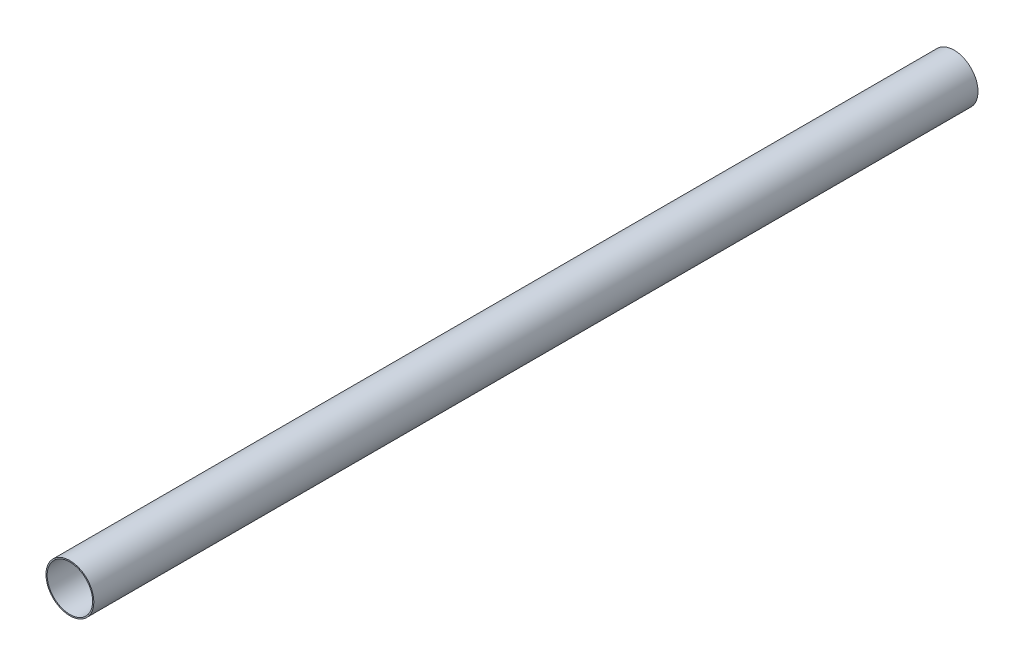
from build123d import *

# Parameters (mm, degrees)
SKETCH1_R           = 15.265
SKETCH1_R_2         = 14.505
BOSS_EXTRUDE1_DEPTH = 563.88


with BuildPart() as part:
    # Sketch1 → Boss-Extrude1 (new body)
    with BuildSketch(Plane.XY):
        Circle(SKETCH1_R)
        Circle(SKETCH1_R_2, mode=Mode.SUBTRACT)
    extrude(amount=BOSS_EXTRUDE1_DEPTH)


solid = part.part
